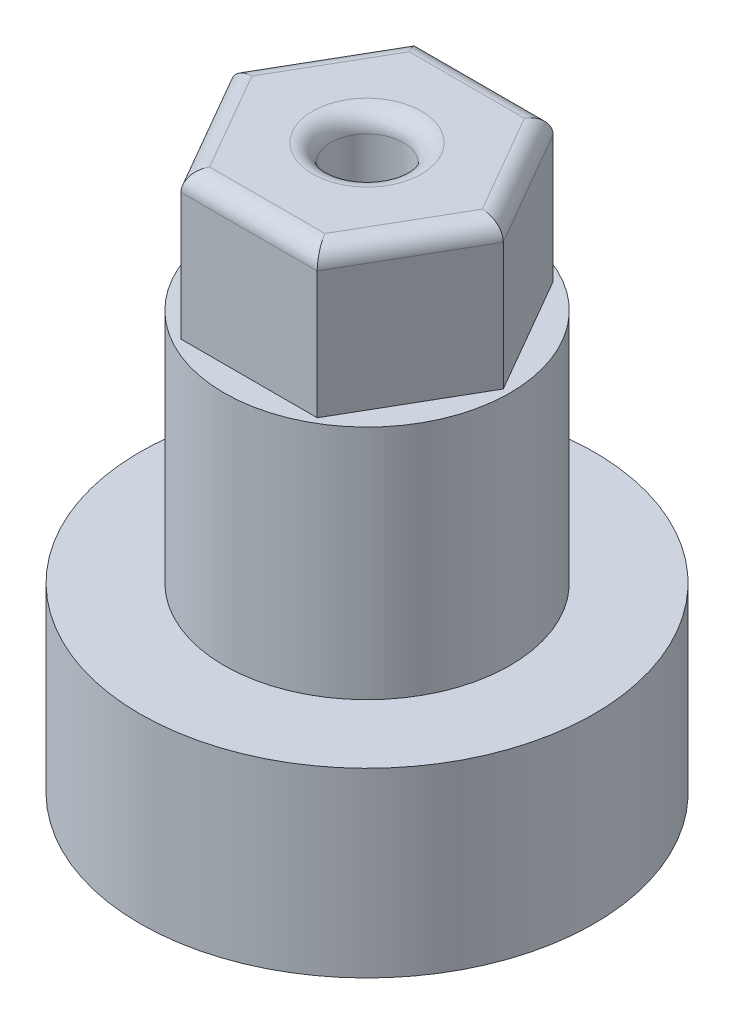
from build123d import *

# Parameters (mm, degrees)
CROQUIS1_R              = 12.5
CROQUIS1_R_2            = 0.75
SALIENTE_EXTRUIR1_DEPTH = 10
CROQUIS2_R              = 7.875
SALIENTE_EXTRUIR2_DEPTH = 13
SALIENTE_EXTRUIR3_DEPTH = 8
CROQUIS4_R              = 2
CORTAR_EXTRUIR1_DEPTH   = 32
REDONDEO1_R             = 1


with BuildPart() as part:
    # Croquis1 → Saliente-Extruir1 (new body)
    with BuildSketch(Plane(origin=(0, 0, 0), x_dir=(1, 0, 0), z_dir=(0, 1, 0))):
        Circle(CROQUIS1_R)
        with Locations((7, 0)):
            Circle(CROQUIS1_R_2, mode=Mode.SUBTRACT)
        with Locations((0, -7)):
            Circle(CROQUIS1_R_2, mode=Mode.SUBTRACT)
        with Locations((-7, 0)):
            Circle(CROQUIS1_R_2, mode=Mode.SUBTRACT)
        with Locations((0, 7)):
            Circle(CROQUIS1_R_2, mode=Mode.SUBTRACT)
    extrude(amount=SALIENTE_EXTRUIR1_DEPTH)

    # Croquis2 → Saliente-Extruir2 (add)
    with BuildSketch(Plane(origin=(0, 10, 0), x_dir=(1, 0, 0), z_dir=(0, 1, 0))):
        Circle(CROQUIS2_R)
    extrude(amount=SALIENTE_EXTRUIR2_DEPTH)

    # Croquis3 → Saliente-Extruir3 (add)
    with BuildSketch(Plane(origin=(0, 23, 0), x_dir=(1, 0, 0), z_dir=(0, 1, 0))):
        Polygon((7.5, 0), (3.75, 6.495190528), (-3.75, 6.495190528), (-7.5, 0), (-3.75, -6.495190528), (3.75, -6.495190528), align=None)
    extrude(amount=SALIENTE_EXTRUIR3_DEPTH)

    # Croquis4 → Cortar-Extruir1 (cut, through all)
    with BuildSketch(Plane(origin=(0, 31, 0), x_dir=(1, 0, 0), z_dir=(0, 1, 0))):
        Circle(CROQUIS4_R)
    extrude(amount=-CORTAR_EXTRUIR1_DEPTH, mode=Mode.SUBTRACT)

    # Redondeo1
    redondeo1_edges = [part.edges().sort_by_distance(p)[0] for p in [
        (5.625, 31, 3.247595264),
        (5.625, 31, -3.247595264),
        (0, 31, -6.495190528),
        (-5.625, 31, -3.247595264),
        (-5.625, 31, 3.247595264),
        (0, 31, 6.495190528),
        (-2, 31, 0),
    ]]
    fillet(redondeo1_edges, radius=REDONDEO1_R)


solid = part.part
